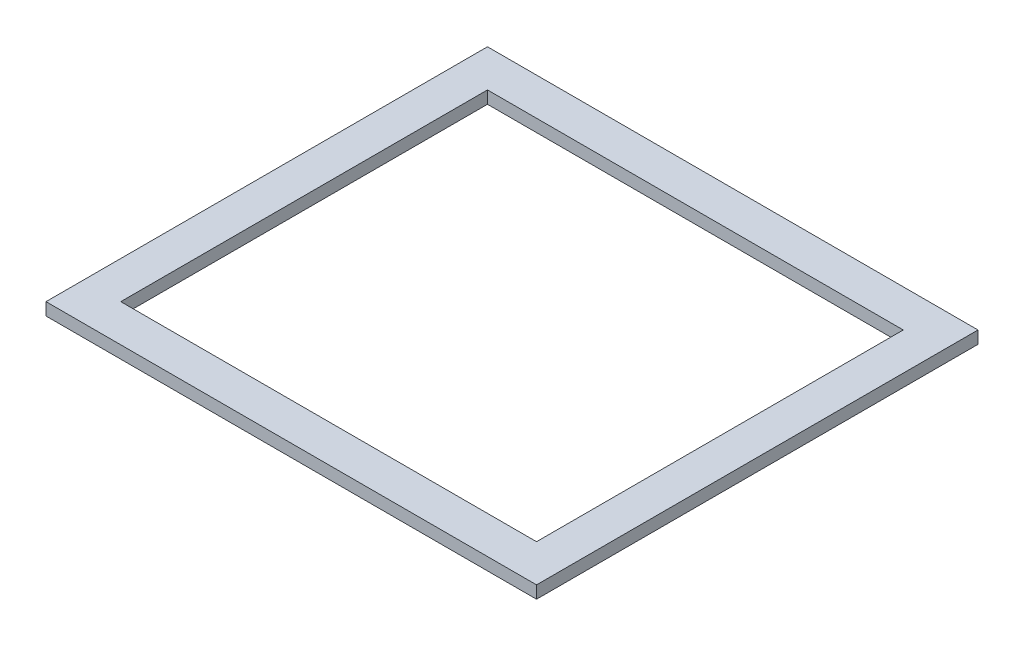
from build123d import *

# Parameters (mm, degrees)
CROQUIS1_W              = 1000
CROQUIS1_H              = 900
CROQUIS1_W_2            = 847.6
CROQUIS1_H_2            = 747.6
SALIENTE_EXTRUIR1_DEPTH = 25.4


with BuildPart() as part:
    # Croquis1 → Saliente-Extruir1 (new body)
    with BuildSketch(Plane(origin=(0, 0, 0), x_dir=(1, 0, 0), z_dir=(0, 1, 0))):
        with Locations((500, -450)):
            Rectangle(CROQUIS1_W, CROQUIS1_H)
        with Locations((500, -450)):
            Rectangle(CROQUIS1_W_2, CROQUIS1_H_2, mode=Mode.SUBTRACT)
    extrude(amount=SALIENTE_EXTRUIR1_DEPTH)


solid = part.part
